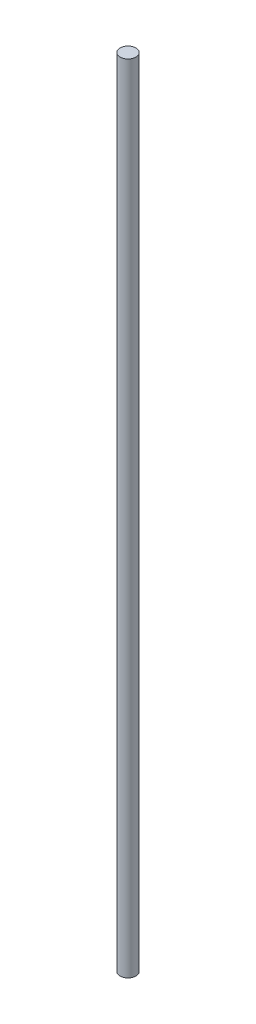
from build123d import *

# Parameters (mm, degrees)
SKETCH2_W = 4
SKETCH2_H = 400


with BuildPart() as part:
    # Sketch2 → Revolve1 (revolve)
    with BuildSketch(Plane.XY):
        with Locations((2, 200)):
            Rectangle(SKETCH2_W, SKETCH2_H)
    revolve(axis=Axis((0, 0, 0), (0, 1, 0)))


solid = part.part
